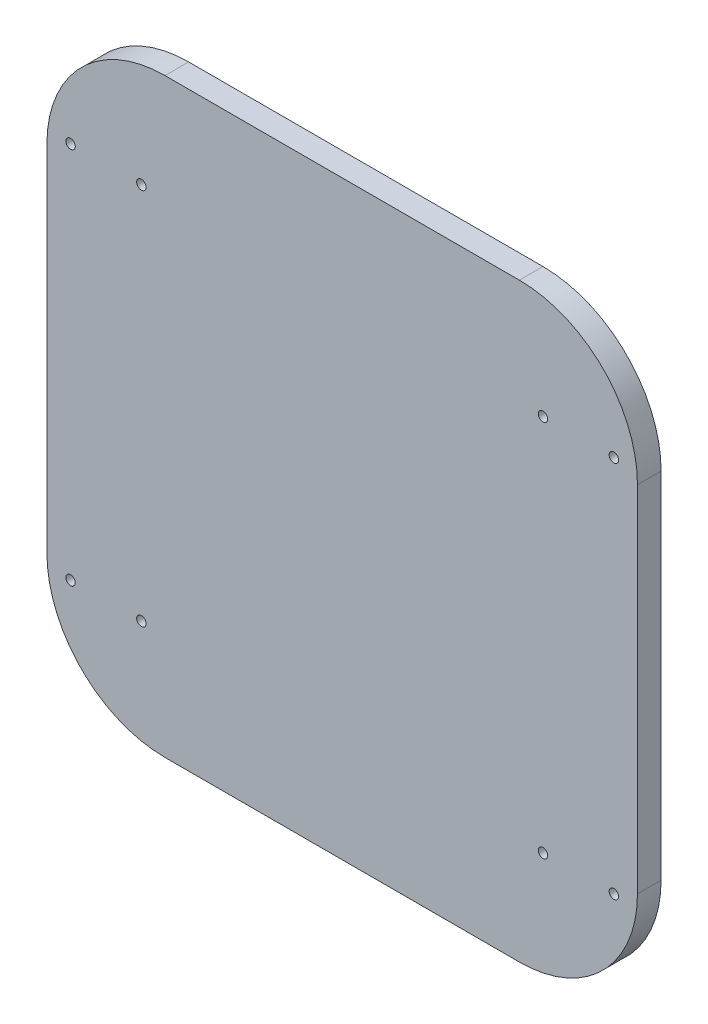
from build123d import *

# Parameters (mm, degrees)
EXTRUDE_1_DEPTH     = 10
SKETCH_2_R          = 2
CUT_EXTRUDE_1_DEPTH = 8
EXTRUDE_2_DEPTH     = 10


with BuildPart() as part:
    # 草图1 → 凸台-拉伸1 (new body)
    with BuildSketch(Plane.XY):
        with BuildLine():
            Line((-75, -125), (75, -125))
            ThreePointArc((75, -125), (110.355339059, -110.355339059), (125, -75))
            Line((125, -75), (125, 75))
            ThreePointArc((125, 75), (110.355339059, 110.355339059), (75, 125))
            Line((75, 125), (-75, 125))
            ThreePointArc((-75, 125), (-110.355339059, 110.355339059), (-125, 75))
            Line((-125, 75), (-125, -75))
            ThreePointArc((-125, -75), (-110.355339059, -110.355339059), (-75, -125))
        make_face()
    extrude(amount=EXTRUDE_1_DEPTH)

    # 草图2 → 切除-拉伸1 (cut)
    with BuildSketch(Plane.XY.offset(10)):
        with Locations((115, 80)):
            Circle(SKETCH_2_R)
        with Locations((85, 80)):
            Circle(SKETCH_2_R)
        with Locations((115, -80)):
            Circle(SKETCH_2_R)
        with Locations((85, -80)):
            Circle(SKETCH_2_R)
        with Locations((-115, -80)):
            Circle(SKETCH_2_R)
        with Locations((-85, -80)):
            Circle(SKETCH_2_R)
        with Locations((-85, 80)):
            Circle(SKETCH_2_R)
        with Locations((-115, 80)):
            Circle(SKETCH_2_R)
    extrude(amount=-CUT_EXTRUDE_1_DEPTH, mode=Mode.SUBTRACT)

    # 草图3 → 凸台-拉伸2 (add)
    with BuildSketch(Plane(origin=(0, 0, 0), x_dir=(-1, 0, 0), z_dir=(0, 0, -1))):
        with BuildLine():
            Line((-20, 96.846443928), (-20, -101.335336728))
            ThreePointArc((-20, -101.335336728), (-21.464466094, -104.870870634), (-25, -106.335336728))
            Line((-25, -106.335336728), (-45, -106.335336728))
            ThreePointArc((-45, -106.335336728), (-48.535533906, -104.870870634), (-50, -101.335336728))
            Line((-50, -101.335336728), (-50, 96.846443928))
            ThreePointArc((-50, 96.846443928), (-48.535533906, 100.381977834), (-45, 101.846443928))
            Line((-45, 101.846443928), (-25, 101.846443928))
            ThreePointArc((-25, 101.846443928), (-21.464466094, 100.381977834), (-20, 96.846443928))
        make_face()
        with BuildLine():
            Line((-70, 96.846443928), (-70, -101.335336728))
            ThreePointArc((-70, -101.335336728), (-71.464466094, -104.870870634), (-75, -106.335336728))
            Line((-75, -106.335336728), (-95, -106.335336728))
            ThreePointArc((-95, -106.335336728), (-98.535533906, -104.870870634), (-100, -101.335336728))
            Line((-100, -101.335336728), (-100, 57.613560287))
            ThreePointArc((-100, 57.613560287), (-94.783283784, 80.504296116), (-85, 101.846443928))
            Line((-85, 101.846443928), (-75, 101.846443928))
            ThreePointArc((-75, 101.846443928), (-71.464466094, 100.381977834), (-70, 96.846443928))
        make_face()
        with BuildLine():
            Line((45, -106.335336728), (25, -106.335336728))
            ThreePointArc((25, -106.335336728), (21.464466094, -104.870870634), (20, -101.335336728))
            Line((20, -101.335336728), (20, 96.846443928))
            ThreePointArc((20, 96.846443928), (21.464466094, 100.381977834), (25, 101.846443928))
            Line((25, 101.846443928), (45, 101.846443928))
            ThreePointArc((45, 101.846443928), (48.535533906, 100.381977834), (50, 96.846443928))
            Line((50, 96.846443928), (50, -101.335336728))
            ThreePointArc((50, -101.335336728), (48.535533906, -104.870870634), (45, -106.335336728))
        make_face()
        with BuildLine():
            Line((95, -106.335336728), (75, -106.335336728))
            ThreePointArc((75, -106.335336728), (71.464466094, -104.870870634), (70, -101.335336728))
            Line((70, -101.335336728), (70, 96.846443928))
            ThreePointArc((70, 96.846443928), (71.464466094, 100.381977834), (75, 101.846443928))
            Line((75, 101.846443928), (85, 101.846443928))
            ThreePointArc((85, 101.846443928), (94.783283784, 80.504296116), (100, 57.613560287))
            Line((100, 57.613560287), (100, -101.335336728))
            ThreePointArc((100, -101.335336728), (98.535533906, -104.870870634), (95, -106.335336728))
        make_face()
    extrude(amount=EXTRUDE_2_DEPTH)


solid = part.part
